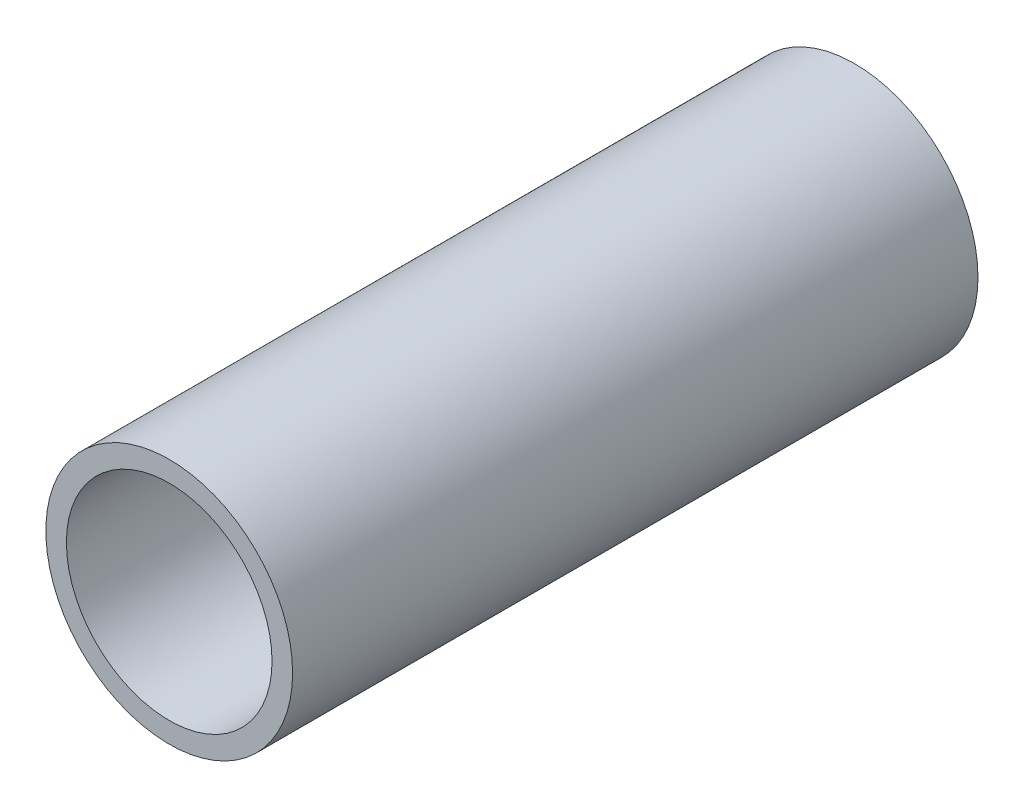
from build123d import *

# Parameters (mm, degrees)
SKETCH1_R           = 18
SKETCH1_R_2         = 15
BOSS_EXTRUDE1_DEPTH = 100


with BuildPart() as part:
    # Sketch1 → Boss-Extrude1 (new body)
    with BuildSketch(Plane.XY):
        Circle(SKETCH1_R)
        Circle(SKETCH1_R_2, mode=Mode.SUBTRACT)
    extrude(amount=BOSS_EXTRUDE1_DEPTH)


solid = part.part
